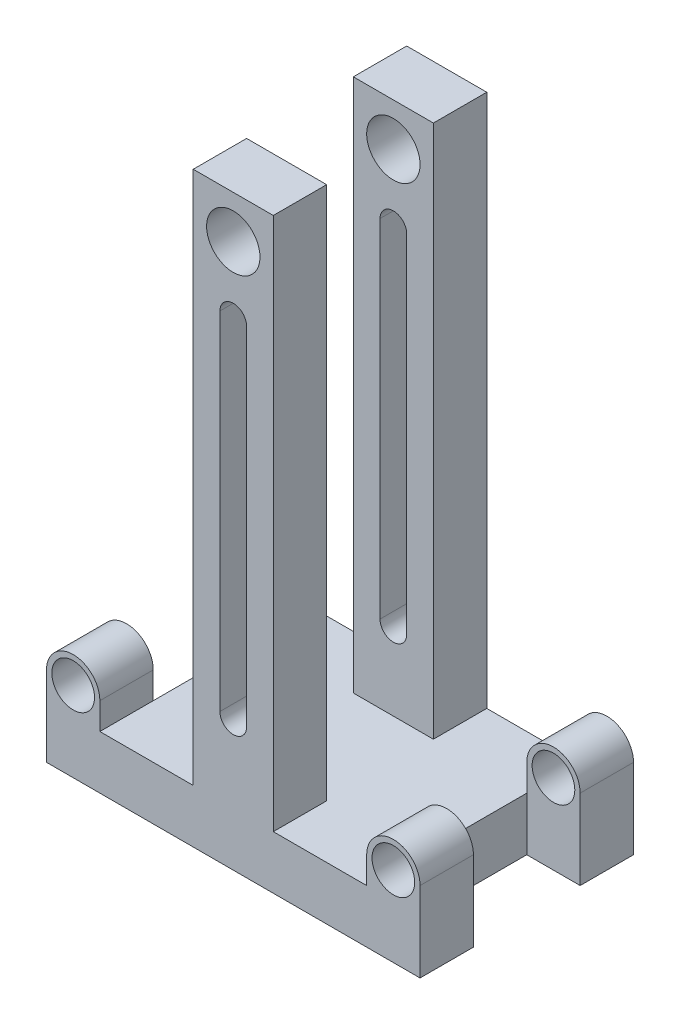
from build123d import *

# Parameters (mm, degrees)
SKETCH1_W           = 38.1
SKETCH1_H           = 254
SKETCH1_R           = 12.7
BOSS_EXTRUDE1_DEPTH = 25.4
SKETCH1_4_W         = 177.8
SKETCH1_4_H         = 25.4
BOSS_EXTRUDE2_DEPTH = 101.6
BOSS_EXTRUDE3_START = 101.6
SKETCH1_5_W         = 38.1
SKETCH1_5_H         = 254
SKETCH1_5_R         = 12.7
BOSS_EXTRUDE3_DEPTH = 25.4
SKETCH2_R           = 12.7
SKETCH2_R_2         = 10.16
BOSS_EXTRUDE4_DEPTH = 101.6
SKETCH3_W           = 25.4
SKETCH3_H           = 50.8
CUT_EXTRUDE1_DEPTH  = 288.648691984


with BuildPart() as part:
    # Sketch1 → Boss-Extrude1 (new body)
    with BuildSketch(Plane.XY):
        Polygon((-88.9, -12.7), (88.9, -12.7), (88.9, 12.7), (19.05, 12.7), (-19.05, 12.7), (-88.9, 12.7), align=None)
        with Locations((0, 139.7)):
            Rectangle(SKETCH1_W, SKETCH1_H)
        with BuildLine():
            ThreePointArc((6.35, 49.53), (0, 43.18), (-6.35, 49.53))
            Line((-6.35, 49.53), (-6.35, 214.63))
            ThreePointArc((-6.35, 214.63), (0, 220.98), (6.35, 214.63))
            Line((6.35, 214.63), (6.35, 49.53))
        make_face(mode=Mode.SUBTRACT)
        with Locations((0, 246.38)):
            Circle(SKETCH1_R, mode=Mode.SUBTRACT)
    extrude(amount=BOSS_EXTRUDE1_DEPTH)

    # Sketch1_4 → Boss-Extrude2 (add)
    with BuildSketch(Plane.XY):
        Rectangle(SKETCH1_4_W, SKETCH1_4_H)
    extrude(amount=BOSS_EXTRUDE2_DEPTH)

    # Sketch1_5 → Boss-Extrude3 (add)
    with BuildSketch(Plane.XY.offset(BOSS_EXTRUDE3_START)):
        Polygon((-88.9, -12.7), (88.9, -12.7), (88.9, 12.7), (19.05, 12.7), (-19.05, 12.7), (-88.9, 12.7), align=None)
        with Locations((0, 139.7)):
            Rectangle(SKETCH1_5_W, SKETCH1_5_H)
        with BuildLine():
            ThreePointArc((6.35, 49.53), (0, 43.18), (-6.35, 49.53))
            Line((-6.35, 49.53), (-6.35, 214.63))
            ThreePointArc((-6.35, 214.63), (0, 220.98), (6.35, 214.63))
            Line((6.35, 214.63), (6.35, 49.53))
        make_face(mode=Mode.SUBTRACT)
        with Locations((0, 246.38)):
            Circle(SKETCH1_5_R, mode=Mode.SUBTRACT)
    extrude(amount=-BOSS_EXTRUDE3_DEPTH)

    # Sketch2 → Boss-Extrude4 (add, through all)
    with BuildSketch(Plane.XY.offset(101.6)):
        with Locations((-76.2, 25.4)):
            Circle(SKETCH2_R)
        with Locations((-76.2, 25.4)):
            Circle(SKETCH2_R_2, mode=Mode.SUBTRACT)
        with BuildLine():
            ThreePointArc((-76.199999961, 12.7), (-85.180256107, 16.419743865), (-88.9, 25.4))
            Line((-88.9, 25.4), (-88.9, 12.7))
            Line((-88.9, 12.7), (-76.199999961, 12.7))
        make_face()
        with BuildLine():
            Line((-63.5, 12.7), (-63.5, 25.4))
            ThreePointArc((-63.5, 25.4), (-67.219743865, 16.419743893), (-76.199999961, 12.7))
            Line((-76.199999961, 12.7), (-63.5, 12.7))
        make_face()
    boss_extrude4 = extrude(amount=-BOSS_EXTRUDE4_DEPTH)

    # Sketch3 → Cut-Extrude1 (cut, symmetric)
    with BuildSketch(Plane(origin=(0, 12.7, 0), x_dir=(1, 0, 0), z_dir=(0, 1, 0))):
        with Locations((-76.2, -50.8)):
            Rectangle(SKETCH3_W, SKETCH3_H)
    cut_extrude1 = extrude(amount=CUT_EXTRUDE1_DEPTH, both=True, mode=Mode.SUBTRACT)

    # Mirror1: Boss-Extrude4, Cut-Extrude1 across plane
    add(boss_extrude4.mirror(Plane(origin=(0, 0, 0), x_dir=(0, 0, 1), z_dir=(1, 0, 0))))
    add(cut_extrude1.mirror(Plane(origin=(0, 0, 0), x_dir=(0, 0, 1), z_dir=(1, 0, 0))), mode=Mode.SUBTRACT)


solid = part.part
